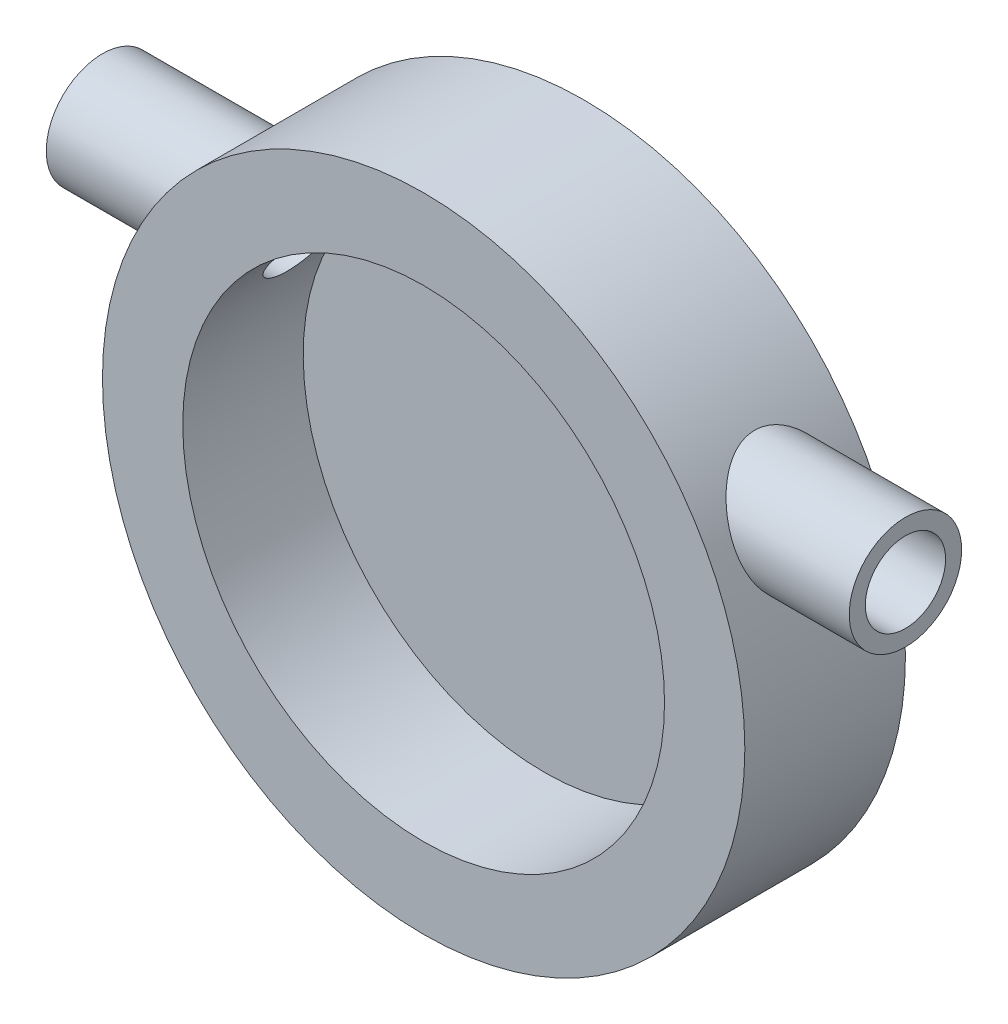
from build123d import *

# Parameters (mm, degrees)
SKETCH1_R                = 40
BOSS_EXTRUDE1_DEPTH      = 20
BOSS_EXTRUDE2_DEPTH      = 50
BOSS_EXTRUDE2_DEPTH_BACK = 50
SKETCH3_R                = 7
SKETCH5_R                = 5
CUT_EXTRUDE2_DEPTH       = 110.544511647
SKETCH2_R                = 30
CUT_EXTRUDE3_DEPTH       = 15


with BuildPart() as part:
    # Sketch1 → Boss-Extrude1 (new body)
    with BuildSketch(Plane.XY):
        Circle(SKETCH1_R)
    extrude(amount=-BOSS_EXTRUDE1_DEPTH)

    # Sketch3 → Boss-Extrude2 (add, two sides: drawn at the far end of the back side and taken through both)
    with BuildSketch(Plane(origin=(0, 0, 0), x_dir=(0, 0, -1), z_dir=(1, 0, 0)).offset(-BOSS_EXTRUDE2_DEPTH_BACK)):
        with Locations((10, 18)):
            Circle(SKETCH3_R)
    extrude(amount=BOSS_EXTRUDE2_DEPTH + BOSS_EXTRUDE2_DEPTH_BACK)

    # Sketch5 → Cut-Extrude2 (cut, through all)
    with BuildSketch(Plane(origin=(50, 0, 0), x_dir=(0, 0, -1), z_dir=(1, 0, 0))):
        with Locations((10, 18)):
            Circle(SKETCH5_R)
    extrude(amount=-CUT_EXTRUDE2_DEPTH, mode=Mode.SUBTRACT)

    # Sketch2 → Cut-Extrude3 (cut)
    with BuildSketch(Plane.XY):
        Circle(SKETCH2_R)
    extrude(amount=-CUT_EXTRUDE3_DEPTH, mode=Mode.SUBTRACT)


solid = part.part
